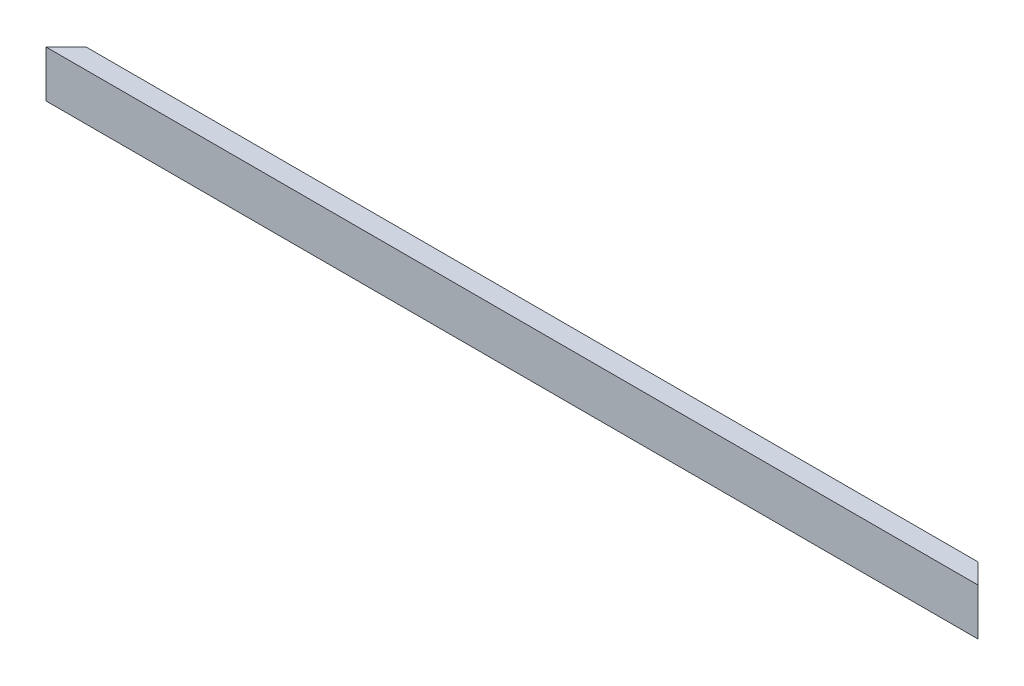
from build123d import *

# Parameters (mm, degrees)
SKETCH1_W           = 1771.65
SKETCH1_H           = 38.1
BOSS_EXTRUDE1_DEPTH = 88.9
CUT_EXTRUDE1_DEPTH  = 89.9


with BuildPart() as part:
    # Sketch1 → Boss-Extrude1 (new body)
    with BuildSketch(Plane(origin=(0, 0, 0), x_dir=(1, 0, 0), z_dir=(0, 1, 0))):
        with Locations((885.825, 19.05)):
            Rectangle(SKETCH1_W, SKETCH1_H)
    extrude(amount=BOSS_EXTRUDE1_DEPTH)

    # Sketch2 → Cut-Extrude1 (cut, through all)
    with BuildSketch(Plane(origin=(0, 0, 0), x_dir=(1, 0, 0), z_dir=(0, 1, 0))):
        Polygon((0, 0), (38.1, 38.1), (0, 38.1), align=None)
        Polygon((1771.65, 0), (1733.55, 38.1), (1771.65, 38.1), align=None)
    extrude(amount=CUT_EXTRUDE1_DEPTH, mode=Mode.SUBTRACT)


solid = part.part
